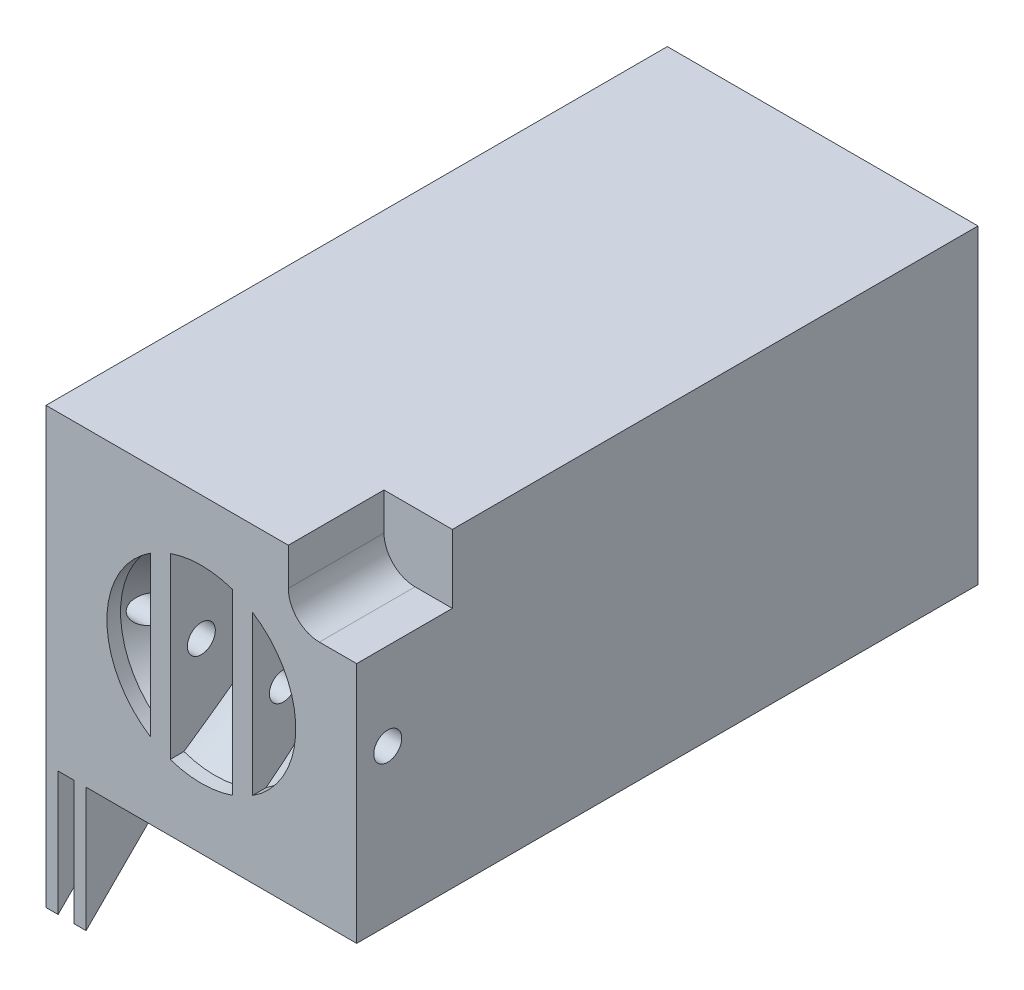
from build123d import *

# Parameters (mm, degrees)
CROQUIS1_W                                           = 50
CROQUIS1_H                                           = 50
CROQUIS1_R                                           = 2
SALIENTE_EXTRUIR2_DEPTH                              = 100
CROQUIS4_W                                           = 3.2
CROQUIS4_H                                           = 40
SALIENTE_EXTRUIR5_DEPTH                              = 10.2
CROQUIS8_R                                           = 4
CORTAR_EXTRUIR3_DEPTH                                = 87.4
CORTAR_EXTRUIR2_START                                = -50
CROQUIS7_R                                           = 2
CORTAR_EXTRUIR2_DEPTH                                = 50
REFRENTADO_PARA_TORNILLO_TAP_N_CON_CABEZ_D           = 4.5
REFRENTADO_PARA_TORNILLO_TAP_N_CON_CABEZ_CSINK_D     = 8.96
REFRENTADO_PARA_TORNILLO_TAP_N_CON_CABEZ_CSINK_ANGLE = 90
SALIENTE_EXTRUIR6_DEPTH                              = 1.95
SALIENTE_EXTRUIR7_START                              = -4.5
SALIENTE_EXTRUIR7_DEPTH                              = 1.95
CORTAR_EXTRUIR4_DEPTH                                = 15.4


with BuildPart() as part:
    # Croquis1 → Saliente-Extruir2 (new body)
    with BuildSketch(Plane.XY):
        Rectangle(CROQUIS1_W, CROQUIS1_H)
        Circle(CROQUIS1_R, mode=Mode.SUBTRACT)
    extrude(amount=SALIENTE_EXTRUIR2_DEPTH)

    # Croquis2 → Cortar-Revolución1 (revolve, cut)
    with BuildSketch(Plane(origin=(0, 0, 0), x_dir=(0, 0, -1), z_dir=(1, 0, 0))):
        Polygon((-100, 15.2), (-100, 0), (-89.8, 0), (-89.8, 10), (-97.8, 15.2), align=None)
    revolve(axis=Axis((0, 0, 100), (0, 0, -1)), mode=Mode.SUBTRACT)

    # Croquis4 → Saliente-Extruir5 (add)
    with BuildSketch(Plane.XY.offset(100)):
        with Locations((-6.6, 0)):
            Rectangle(CROQUIS4_W, CROQUIS4_H)
        with Locations((6.6, 0)):
            Rectangle(CROQUIS4_W, CROQUIS4_H)
    extrude(amount=-SALIENTE_EXTRUIR5_DEPTH)

    # Croquis8 → Cortar-Extruir3 (cut)
    with BuildSketch(Plane.XY.offset(89.8)):
        Circle(CROQUIS8_R)
    extrude(amount=-CORTAR_EXTRUIR3_DEPTH, mode=Mode.SUBTRACT)

    # Croquis7 → Cortar-Extruir2 (cut)
    with BuildSketch(Plane.ZY.offset(25).offset(CORTAR_EXTRUIR2_START)):
        with Locations((95, 0)):
            Circle(CROQUIS7_R)
    extrude(amount=CORTAR_EXTRUIR2_DEPTH, mode=Mode.SUBTRACT)

    # Refrentado para tornillo tapón con cabeza plana de clavija de M41 (through all)
    with Locations(Plane.ZY.offset(25)):
        with Locations((95, 0)):
            CounterSinkHole(REFRENTADO_PARA_TORNILLO_TAP_N_CON_CABEZ_D / 2, REFRENTADO_PARA_TORNILLO_TAP_N_CON_CABEZ_CSINK_D / 2, counter_sink_angle=REFRENTADO_PARA_TORNILLO_TAP_N_CON_CABEZ_CSINK_ANGLE)

    # Croquis12 → Saliente-Extruir6 (add)
    with BuildSketch(Plane.ZY.offset(25)):
        Polygon((100, -25), (80, -25), (100, -45), align=None)
    extrude(amount=-SALIENTE_EXTRUIR6_DEPTH)

    # Croquis12_2 → Saliente-Extruir7 (add)
    with BuildSketch(Plane.ZY.offset(25).offset(SALIENTE_EXTRUIR7_START)):
        Polygon((100, -25), (80, -25), (100, -45), align=None)
    extrude(amount=-SALIENTE_EXTRUIR7_DEPTH)

    # Croquis13 → Cortar-Extruir4 (cut)
    with BuildSketch(Plane.XY.offset(100)):
        with BuildLine():
            Line((25, 25), (25, 14))
            Line((25, 14), (19, 14))
            ThreePointArc((19, 14), (15.464466094, 15.464466094), (14, 19))
            Line((14, 19), (14, 25))
            Line((14, 25), (25, 25))
        make_face()
    extrude(amount=-CORTAR_EXTRUIR4_DEPTH, mode=Mode.SUBTRACT)


solid = part.part
